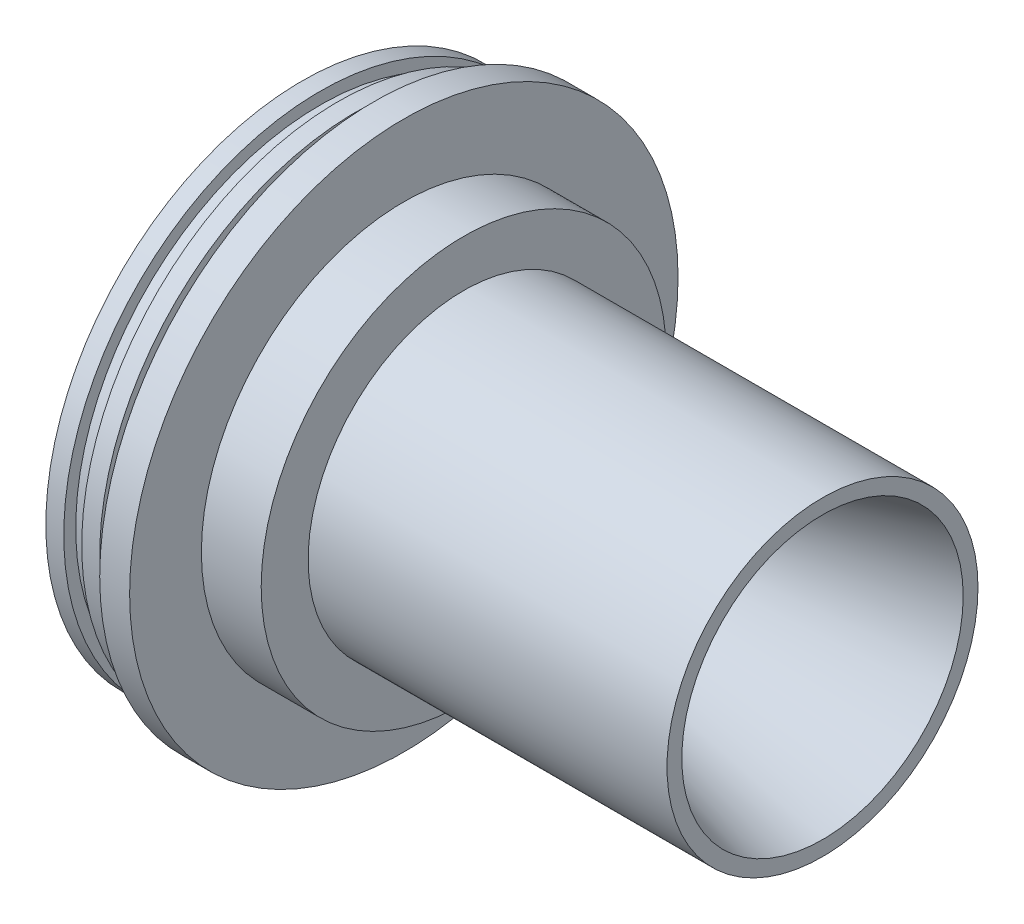
from build123d import *


with BuildPart() as part:
    # Sketch1 → Revolve1 (revolve)
    with BuildSketch(Plane.XY):
        with BuildLine():
            Line((-87, 41.080611397), (-60.892786886, 14.973398282))
            ThreePointArc((-60.892786886, 14.973398282), (-54.168470844, 11.091112606), (-46.403899491, 11.091112606))
            Line((-46.403899491, 11.091112606), (0, 23.525))
            Line((0, 23.525), (0, 26))
            Line((0, 26), (-60, 26))
            Line((-60, 26), (-60, 33.85))
            Line((-60, 33.85), (-70, 33.85))
            Line((-70, 33.85), (-70, 45.85))
            Line((-70, 45.85), (-75, 45.85))
            Line((-75, 45.85), (-75, 40.86))
            Line((-75, 40.86), (-78, 40.86))
            Line((-78, 40.86), (-78, 42.86))
            Line((-78, 42.86), (-81, 42.86))
            Line((-81, 42.86), (-81, 40.86))
            Line((-81, 40.86), (-84, 40.86))
            Line((-84, 40.86), (-84, 42.86))
            Line((-84, 42.86), (-87, 42.86))
            Line((-87, 42.86), (-87, 41.080611397))
        make_face()
    revolve(axis=Axis((0, 0, 0), (-1, 0, 0)))


solid = part.part
